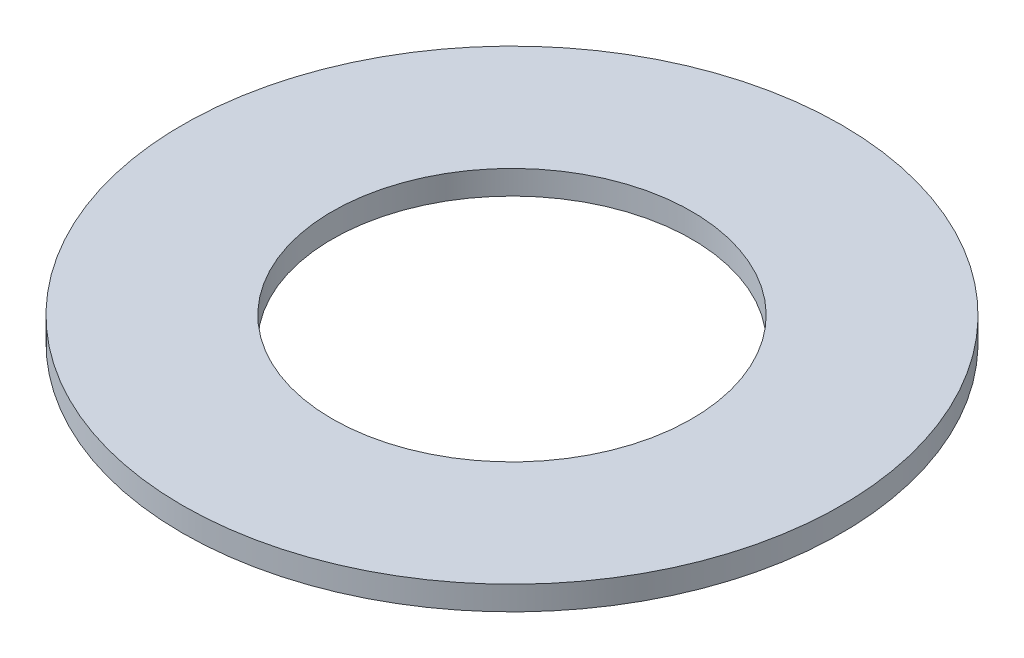
from build123d import *

# Parameters (mm, degrees)
SKETCH1_R           = 27.5
SKETCH1_R_2         = 15
BOSS_EXTRUDE1_DEPTH = 2


with BuildPart() as part:
    # Sketch1 → Boss-Extrude1 (new body)
    with BuildSketch(Plane(origin=(0, 0, 0), x_dir=(1, 0, 0), z_dir=(0, 1, 0))):
        Circle(SKETCH1_R)
        Circle(SKETCH1_R_2, mode=Mode.SUBTRACT)
    extrude(amount=BOSS_EXTRUDE1_DEPTH)


solid = part.part
